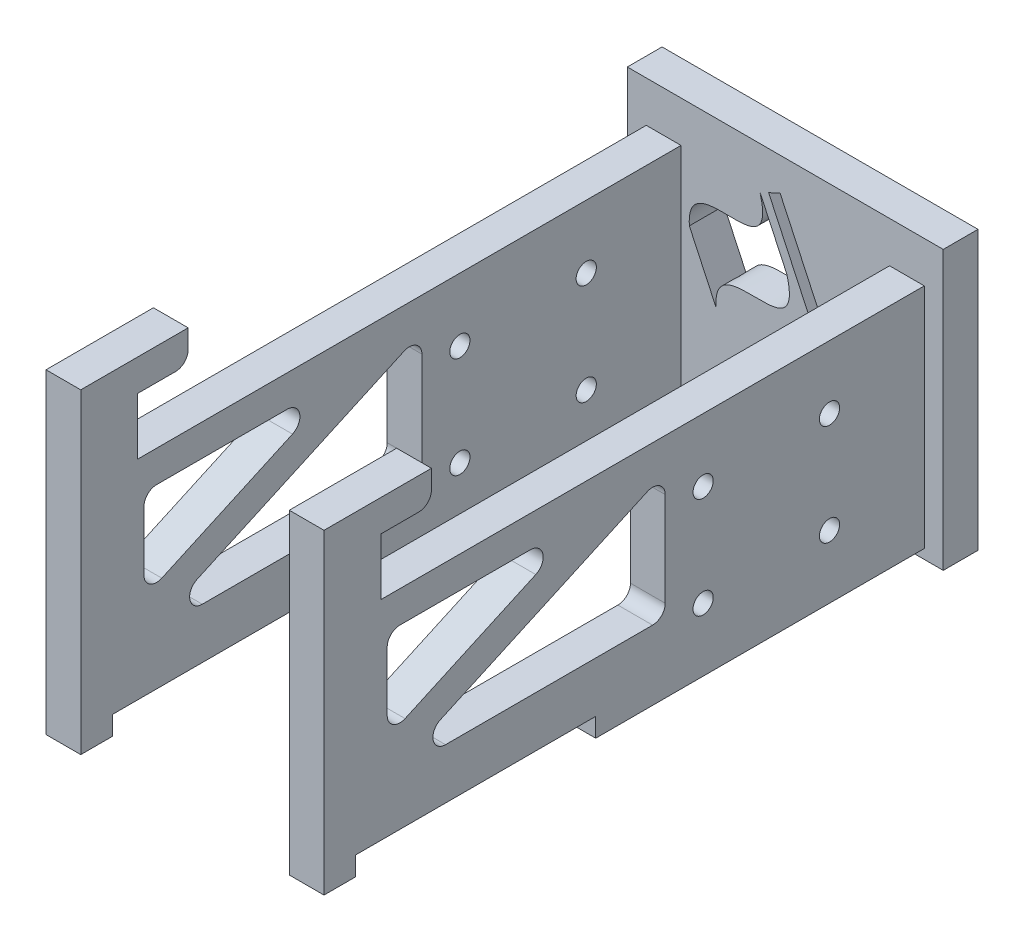
from build123d import *

# Parameters (mm, degrees)
SKETCH_1_W          = 50
SKETCH_1_H          = 40
SKETCH_1_W_2        = 5.5
SKETCH_1_H_2        = 15
EXTRUDE_1_DEPTH     = 5.5
EXTRUDE_2_DEPTH     = 5.5
SKETCH_8_W          = 5.5
SKETCH_8_H          = 38
CUT_EXTRUDE_2_DEPTH = 3
SKETCH_19_R         = 1.6
CUT_EXTRUDE_6_DEPTH = 48.0000001
EXTRUDE_3_DEPTH     = 5.5
SKETCH_21_W         = 50
SKETCH_21_H         = 4
EXTRUDE_4_DEPTH     = 5.5


with BuildPart() as part:
    # ｽｹｯﾁ1 → ﾎﾞｽ - 押し出し1 (new body)
    with BuildSketch(Plane.XY):
        Rectangle(SKETCH_1_W, SKETCH_1_H)
        with Locations((-19.25, 0)):
            Rectangle(SKETCH_1_W_2, SKETCH_1_H_2, mode=Mode.SUBTRACT)
        with Locations((19.25, 0)):
            Rectangle(SKETCH_1_W_2, SKETCH_1_H_2, mode=Mode.SUBTRACT)
        with BuildLine():
            Line((-15.184159493, 7.131957878), (-10.957976876, -1.931119992))
            add(Edge.make_bspline(
                [(0.232480079, 8.26018902), (3.294805184, -2.820777733), (-11.603430093, 7.575468843), (-10.957976876, -1.931119992)],
                knots=[0, 0, 0, 0, 1, 1, 1, 1], degree=3))
            Line((0.232480079, 8.26018902), (-3.993702538, 17.323266891))
            add(Edge.make_bspline(
                [(-3.993702538, 17.323266891), (-0.931377433, 6.242300138), (-15.829612711, 16.638546714), (-15.184159493, 7.131957878)],
                knots=[0, 0, 0, 0, 1, 1, 1, 1], degree=3))
        make_face(mode=Mode.SUBTRACT)
        Polygon((-2.635695691, 17.956515883), (-0.823080117, 18.801752407), (13.968559044, -12.91902014), (12.155943469, -13.764256663), align=None, mode=Mode.SUBTRACT)
    extrude(amount=EXTRUDE_1_DEPTH)

    # ｽｹｯﾁ21 → ﾎﾞｽ - 押し出し4 (add)
    with BuildSketch(Plane(origin=(0, 0, 0), x_dir=(-1, 0, 0), z_dir=(0, 0, -1))):
        with Locations((0, 22)):
            Rectangle(SKETCH_21_W, SKETCH_21_H)
    extrude(amount=-EXTRUDE_4_DEPTH)


with BuildPart() as body_2:
    # ｽｹｯﾁ2 → ﾎﾞｽ - 押し出し2 (new body)
    with BuildSketch(Plane.ZY.offset(16.5)):
        Polygon((0, 7.5), (5.5, 7.5), (5.5, 17.5), (100.5, 17.5), (100.5, -18.5), (5.5, -18.5), (5.5, -7.5), (0, -7.5), align=None)
    extrude(amount=EXTRUDE_2_DEPTH)

    # ｽｹｯﾁ8 → ｶｯﾄ - 押し出し2 (cut)
    with BuildSketch(Plane.XZ.offset(18.5)):
        with Locations((-19.25, 76.5)):
            Rectangle(SKETCH_8_W, SKETCH_8_H)
    extrude(amount=-CUT_EXTRUDE_2_DEPTH, mode=Mode.SUBTRACT)

    # ｽｹｯﾁ19 → ｶｯﾄ - 押し出し6 (cut, through all)
    with BuildSketch(Plane.ZY.offset(22)):
        with Locations((20.5, 7.5)):
            Circle(SKETCH_19_R)
        with Locations((20.5, -8.5)):
            Circle(SKETCH_19_R)
        with Locations((40.5, -8.5)):
            Circle(SKETCH_19_R)
        with Locations((40.5, 7.5)):
            Circle(SKETCH_19_R)
        with BuildLine():
            Line((46.5, 9.393991641), (46.5, -5.5))
            ThreePointArc((46.5, -5.5), (47.085786438, -6.914213562), (48.5, -7.5))
            Line((48.5, -7.5), (81.266781611, -7.5))
            ThreePointArc((81.266781611, -7.5), (83.221451136, -5.923399392), (82.094387499, -3.679267045))
            Line((82.094387499, -3.679267045), (49.327605889, 11.214724596))
            ThreePointArc((49.327605889, 11.214724596), (47.417228505, 11.075540299), (46.5, 9.393991641))
        make_face()
        with BuildLine():
            Line((67.816264363, 12.5), (88.5, 12.5))
            ThreePointArc((88.5, 12.5), (89.914213562, 11.914213562), (90.5, 10.5))
            Line((90.5, 10.5), (90.5, 1.098301983))
            ThreePointArc((90.5, 1.098301983), (89.582771495, -0.583246675), (87.672394111, -0.722430972))
            Line((87.672394111, -0.722430972), (66.988658474, 8.679267045))
            ThreePointArc((66.988658474, 8.679267045), (65.861594837, 10.923399392), (67.816264363, 12.5))
        make_face()
    extrude(amount=-CUT_EXTRUDE_6_DEPTH, mode=Mode.SUBTRACT)

    # ｽｹｯﾁ20 → ﾎﾞｽ - 押し出し3 (add)
    with BuildSketch(Plane.ZY.offset(22)):
        with BuildLine():
            Line((91.5, 17.5), (91.5, 26.5))
            Line((91.5, 26.5), (85.5, 26.5))
            ThreePointArc((85.5, 26.5), (84.085786438, 27.085786438), (83.5, 28.5))
            Line((83.5, 28.5), (83.5, 31.5))
            Line((83.5, 31.5), (100.5, 31.5))
            Line((100.5, 31.5), (100.5, 17.5))
            Line((100.5, 17.5), (91.5, 17.5))
        make_face()
    extrude(amount=-EXTRUDE_3_DEPTH)


with BuildPart() as body_3:
    # ﾐﾗｰ1: mirrored copy
    add(body_2.part.mirror(Plane(origin=(0, 0, 0), x_dir=(0, 0, 1), z_dir=(1, 0, 0))))


solid = Compound([part.part, body_2.part, body_3.part])
